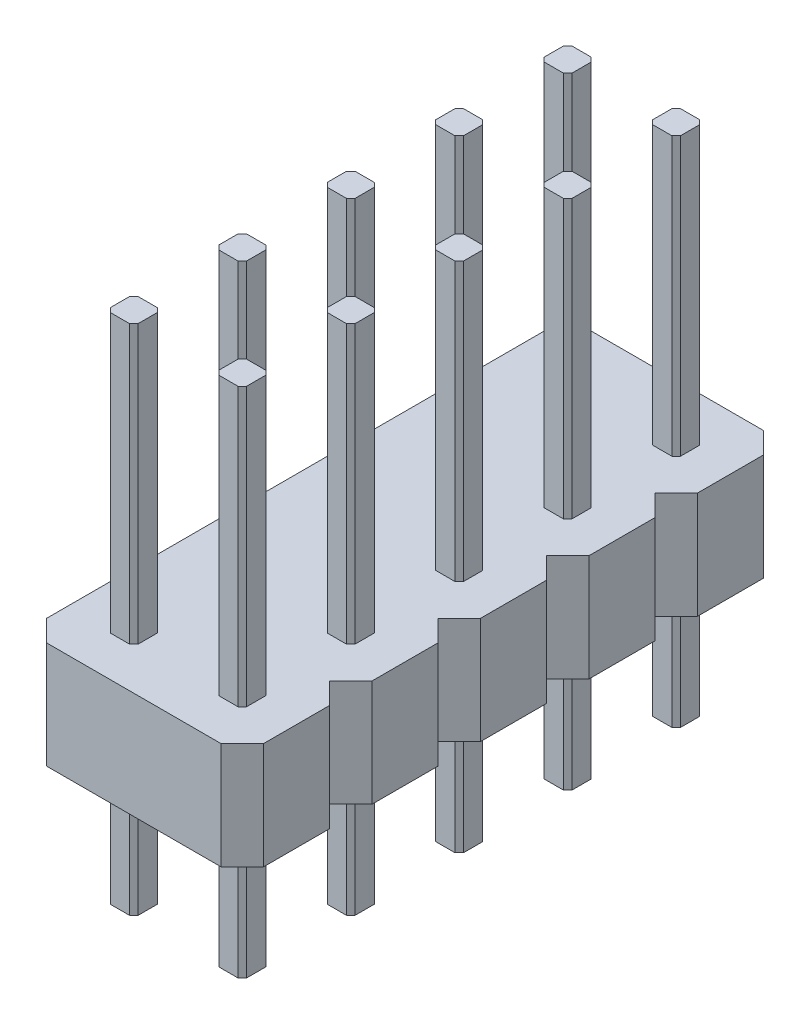
from build123d import *

# Parameters (mm, degrees)
BOSS_EXTRUDE1_DEPTH = 12
LPATTERN2_COUNT     = 2
LPATTERN2_PITCH     = 2.54
BOSS_EXTRUDE2_DEPTH = 2.5
LPATTERN3_COUNT     = 5
LPATTERN3_PITCH     = 2.54


with BuildPart() as part:
    # Sketch1 → Boss-Extrude1 (new body)
    with BuildSketch(Plane(origin=(0, 0, 0), x_dir=(1, 0, 0), z_dir=(0, 1, 0))):
        Polygon((-0.325, -0.225), (-0.225, -0.325), (0.225, -0.325), (0.325, -0.225), (0.325, 0.225), (0.225, 0.325), (-0.225, 0.325), (-0.325, 0.225), align=None)
    extrude(amount=BOSS_EXTRUDE1_DEPTH)


with BuildPart() as lpattern2_1:
    # LPattern2: pattern copy
    add(part.part.moved(Location(Vector(1, 0, 0) * (1 * LPATTERN2_PITCH))))


with BuildPart() as part_1:
    add(part.part)

    add(lpattern2_1.part)  # Boss-Extrude2 merges LPattern2_1
    # Sketch2 → Boss-Extrude2 (add)
    with BuildSketch(Plane(origin=(0, 3, 0), x_dir=(-1, 0, 0), z_dir=(0, -1, 0))):
        Polygon((-3.81, 0.77), (-3.31, 1.27), (0.77, 1.27), (1.27, 0.77), (1.27, -0.77), (0.77, -1.27), (-3.31, -1.27), (-3.81, -0.77), align=None)
    extrude(amount=-BOSS_EXTRUDE2_DEPTH)


with BuildPart() as lpattern3_1:
    # LPattern3: pattern copy
    add(part_1.part.moved(Location(Vector(0, 0, -1) * (1 * LPATTERN3_PITCH))))


with BuildPart() as lpattern3_2:
    # LPattern3: pattern copy
    add(part_1.part.moved(Location(Vector(0, 0, -1) * (2 * LPATTERN3_PITCH))))


with BuildPart() as lpattern3_3:
    # LPattern3: pattern copy
    add(part_1.part.moved(Location(Vector(0, 0, -1) * (3 * LPATTERN3_PITCH))))


with BuildPart() as lpattern3_4:
    # LPattern3: pattern copy
    add(part_1.part.moved(Location(Vector(0, 0, -1) * (4 * LPATTERN3_PITCH))))


with BuildPart() as part_2:
    add(part_1.part)

    # Combine1: union LPattern3_1, LPattern3_2, LPattern3_3, LPattern3_4
    add(lpattern3_1.part)
    add(lpattern3_2.part)
    add(lpattern3_3.part)
    add(lpattern3_4.part)


solid = part_2.part
